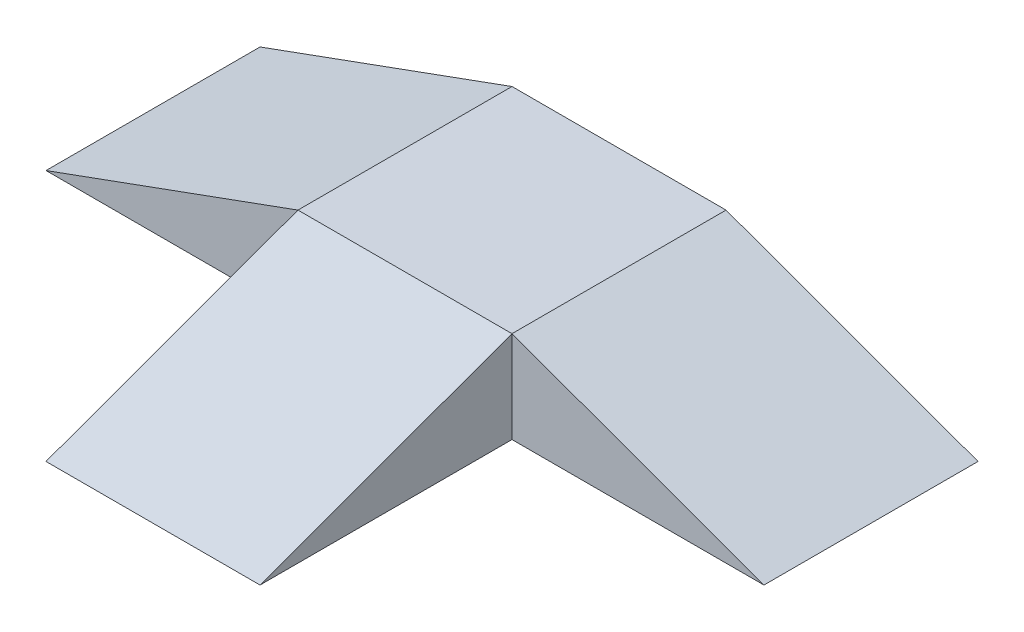
from build123d import *

# Parameters (mm, degrees)
RAMPBASE_W          = 350
RAMPBASE_H          = 350
BOSS_EXTRUDE1_DEPTH = 150
BOSS_EXTRUDE3_DEPTH = 350
BOSS_EXTRUDE5_DEPTH = 350


with BuildPart() as part:
    # rampbase → Boss-Extrude1 (new body)
    with BuildSketch(Plane(origin=(0, 0, 0), x_dir=(1, 0, 0), z_dir=(0, 1, 0))):
        Rectangle(RAMPBASE_W, RAMPBASE_H)
    extrude(amount=BOSS_EXTRUDE1_DEPTH)

    # Sketch6 → Boss-Extrude3 (add)
    with BuildSketch(Plane(origin=(175, 0, 0), x_dir=(0, 0, -1), z_dir=(1, 0, 0))):
        Polygon((-175, 150), (-175, 0), (-587, 0), align=None)
    extrude(amount=-BOSS_EXTRUDE3_DEPTH)

    # Sketch7 → Boss-Extrude5 (add)
    with BuildSketch(Plane(origin=(0, 0, -175), x_dir=(-1, 0, 0), z_dir=(0, 0, -1))):
        Polygon((175, 150), (175, 0), (587, 0), align=None)
        Polygon((-175, 0), (-587, 0), (-175, 150), align=None)
    extrude(amount=-BOSS_EXTRUDE5_DEPTH)


solid = part.part
